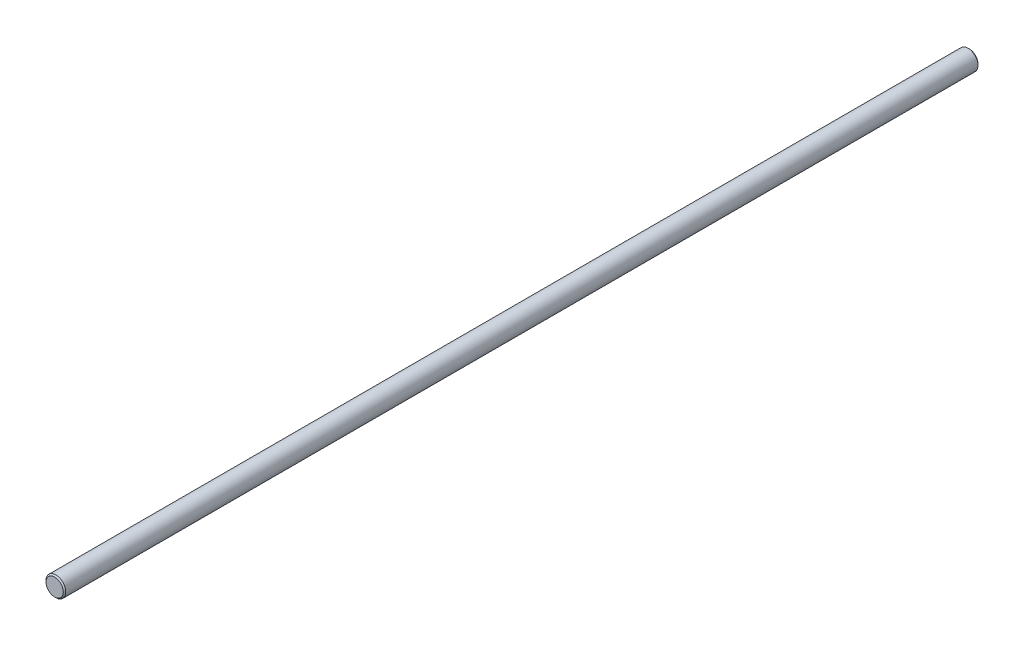
from build123d import *

# Parameters (mm, degrees)
SKETCH1_R           = 4
BOSS_EXTRUDE1_DEPTH = 370
CHAMFER1_SIZE       = 0.5


with BuildPart() as part:
    # Sketch1 → Boss-Extrude1 (new body)
    with BuildSketch(Plane.XY):
        Circle(SKETCH1_R)
    extrude(amount=-BOSS_EXTRUDE1_DEPTH)

    # Chamfer1
    chamfer1_edges = [part.edges().sort_by_distance(p)[0] for p in [
        (-4, 0, 0),
        (-4, 0, -370),
    ]]
    chamfer(chamfer1_edges, length=CHAMFER1_SIZE)


solid = part.part
